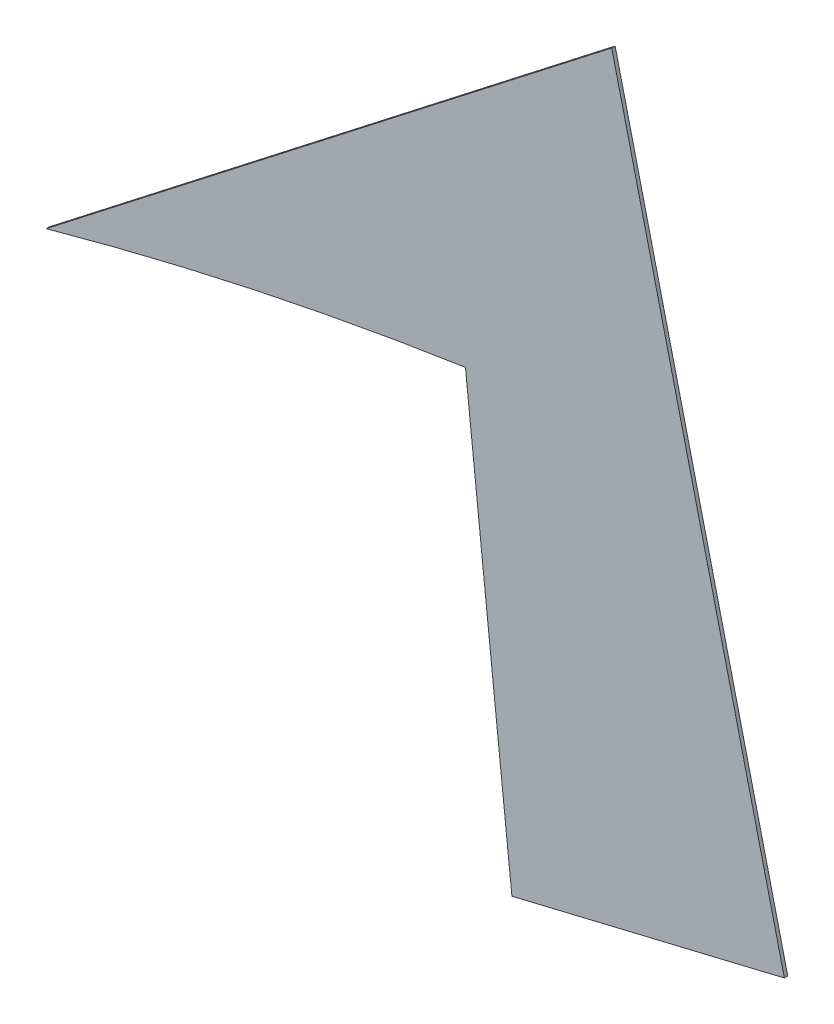
from build123d import *

# Parameters (mm, degrees)
SALIENTE_EXTRUIR1_DEPTH = 0.1


with BuildPart() as part:
    # Model → Saliente-Extruir1 (new body)
    with BuildSketch(Plane.XY):
        with BuildLine():
            Line((24.573492595, 10.397787824), (16.586059329, 8.480394017))
            Line((16.586059329, 8.480394017), (15.223673977, 21.22645362))
            ThreePointArc((15.223673977, 21.22645362), (9.038896644, 20.100865764), (2.933605753, 18.6029199))
            Line((2.933605753, 18.6029199), (19.512585392, 31.480394017))
            Line((19.512585392, 31.480394017), (24.573492595, 10.397787824))
        make_face()
    extrude(amount=SALIENTE_EXTRUIR1_DEPTH)


solid = part.part
